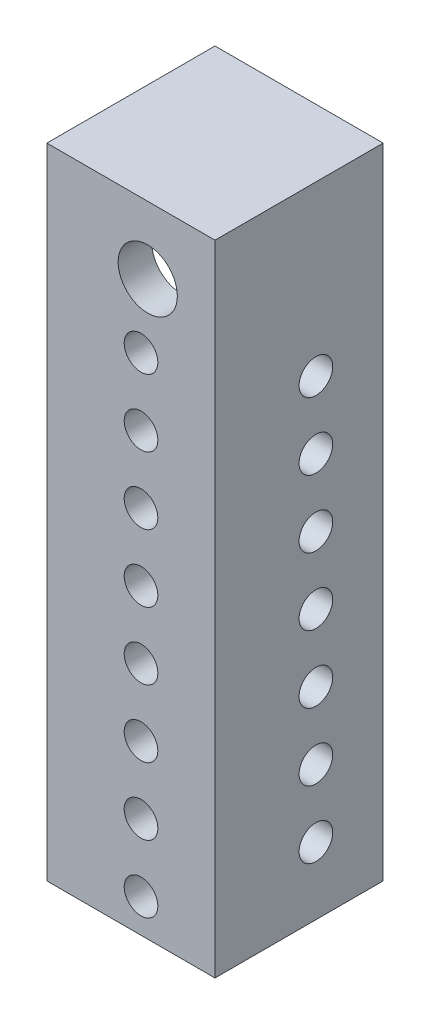
from build123d import *

# Parameters (mm, degrees)
SKETCH2_W           = 63.5
SKETCH2_H           = 63.5
BOSS_EXTRUDE1_DEPTH = 241.3
SKETCH4_W           = 50.8
SKETCH4_H           = 50.8
CUT_EXTRUDE1_DEPTH  = 95.25
SKETCH5_R           = 6.35
CUT_EXTRUDE2_DEPTH  = 64.5
SKETCH6_R           = 6.35
CUT_EXTRUDE3_DEPTH  = 12.7
CUT_EXTRUDE4_DEPTH  = 21.828
CUT_EXTRUDE8_START  = -17.272
CUT_EXTRUDE8_DEPTH  = 17.272
SKETCH43_W          = 10.16
SKETCH43_H          = 8.89
BOSS_EXTRUDE4_DEPTH = 10.16
SKETCH46_R          = 2.032
CUT_EXTRUDE10_DEPTH = 58.674
FILLET6_R           = 3.81
SKETCH48_R          = 11.176
CUT_EXTRUDE12_DEPTH = 12.7


with BuildPart() as part:
    # Sketch2 → Boss-Extrude1 (new body)
    with BuildSketch(Plane(origin=(0, 0, 0), x_dir=(1, 0, 0), z_dir=(0, 1, 0))):
        with Locations((-9.601422319, 6.627899344)):
            Rectangle(SKETCH2_W, SKETCH2_H)
    extrude(amount=BOSS_EXTRUDE1_DEPTH)

    # Sketch4 → Cut-Extrude1 (cut, symmetric)
    with BuildSketch(Plane(origin=(0, 116.078, 0), x_dir=(1, 0, 0), z_dir=(0, 1, 0))):
        with Locations((-15.951422319, 12.977899344)):
            Rectangle(SKETCH4_W, SKETCH4_H)
    extrude(amount=CUT_EXTRUDE1_DEPTH, both=True, mode=Mode.SUBTRACT)

    # Sketch5 → Cut-Extrude2 (cut, through all)
    with BuildSketch(Plane.XY.offset(25.122100656)):
        with Locations((-5.791422319, 12.7)):
            Circle(SKETCH5_R)
        with Locations((-5.791422319, 38.1)):
            Circle(SKETCH5_R)
        with Locations((-5.791422319, 63.5)):
            Circle(SKETCH5_R)
        with Locations((-5.791422319, 88.9)):
            Circle(SKETCH5_R)
        with Locations((-5.791422319, 114.3)):
            Circle(SKETCH5_R)
        with Locations((-5.791422319, 139.7)):
            Circle(SKETCH5_R)
        with Locations((-5.791422319, 165.1)):
            Circle(SKETCH5_R)
        with Locations((-5.791422319, 190.5)):
            Circle(SKETCH5_R)
    extrude(amount=-CUT_EXTRUDE2_DEPTH, mode=Mode.SUBTRACT)

    # Sketch6 → Cut-Extrude3 (cut)
    with BuildSketch(Plane(origin=(22.148577681, 0, 0), x_dir=(0, 0, -1), z_dir=(1, 0, 0))):
        with Locations((12.977899344, 25.4)):
            Circle(SKETCH6_R)
        with Locations((12.977899344, 50.8)):
            Circle(SKETCH6_R)
        with Locations((12.977899344, 76.2)):
            Circle(SKETCH6_R)
        with Locations((12.977899344, 101.6)):
            Circle(SKETCH6_R)
        with Locations((12.977899344, 127)):
            Circle(SKETCH6_R)
        with Locations((12.977899344, 152.4)):
            Circle(SKETCH6_R)
        with Locations((12.977899344, 177.8)):
            Circle(SKETCH6_R)
    extrude(amount=-CUT_EXTRUDE3_DEPTH, mode=Mode.SUBTRACT)

    # Sketch7 → Cut-Extrude4 (cut, through all)
    with BuildSketch(Plane(origin=(0, 20.828, 0), x_dir=(1, 0, 0), z_dir=(0, 1, 0))):
        Polygon((-41.351422319, 38.377899344), (9.448577681, 38.377899344), (9.448577681, 0.277899344), (9.448577681, -12.422100656), (-3.251422319, -12.422100656), (-41.351422319, -12.422100656), align=None)
    extrude(amount=-CUT_EXTRUDE4_DEPTH, mode=Mode.SUBTRACT)

    # Sketch42 → Cut-Extrude8 (cut)
    with BuildSketch(Plane.XZ.offset(-211.328).offset(CUT_EXTRUDE8_START)):
        Polygon((-3.251422319, 12.422100656), (9.448577681, 12.422100656), (9.448577681, -0.277899344), (9.448577681, -38.377899344), (-41.351422319, -38.377899344), (-41.351422319, 12.422100656), align=None)
    extrude(amount=CUT_EXTRUDE8_DEPTH, mode=Mode.SUBTRACT)

    # Sketch43 → Boss-Extrude4 (add)
    with BuildSketch(Plane(origin=(0, 228.6, 0), x_dir=(1, 0, 0), z_dir=(0, 1, 0))):
        with Locations((-5.791422319, 29.106899344)):
            Rectangle(SKETCH43_W, SKETCH43_H)
        with Locations((-5.791422319, 12.342899344)):
            Rectangle(SKETCH43_W, SKETCH43_H)
    extrude(amount=-BOSS_EXTRUDE4_DEPTH)

    # Sketch46 → Cut-Extrude10 (cut)
    with BuildSketch(Plane(origin=(0, 0, -33.551899344), x_dir=(-1, 0, 0), z_dir=(0, 0, -1))):
        with Locations((5.791422319, 223.52)):
            Circle(SKETCH46_R)
    extrude(amount=-CUT_EXTRUDE10_DEPTH, mode=Mode.SUBTRACT)

    # Fillet6
    fillet6_edges = [part.edges().sort_by_distance(p)[0] for p in [
        (-10.871422319, 218.44, -29.106899344),
        (-0.711422319, 218.44, -29.106899344),
        (-10.871422319, 218.44, -12.342899344),
        (-0.711422319, 218.44, -12.342899344),
    ]]
    fillet(fillet6_edges, radius=FILLET6_R)

    # Sketch48 → Cut-Extrude12 (cut)
    with BuildSketch(Plane.XY.offset(25.122100656)):
        with Locations((-3.251422319, 215.9)):
            Circle(SKETCH48_R)
    extrude(amount=-CUT_EXTRUDE12_DEPTH, mode=Mode.SUBTRACT)


solid = part.part
